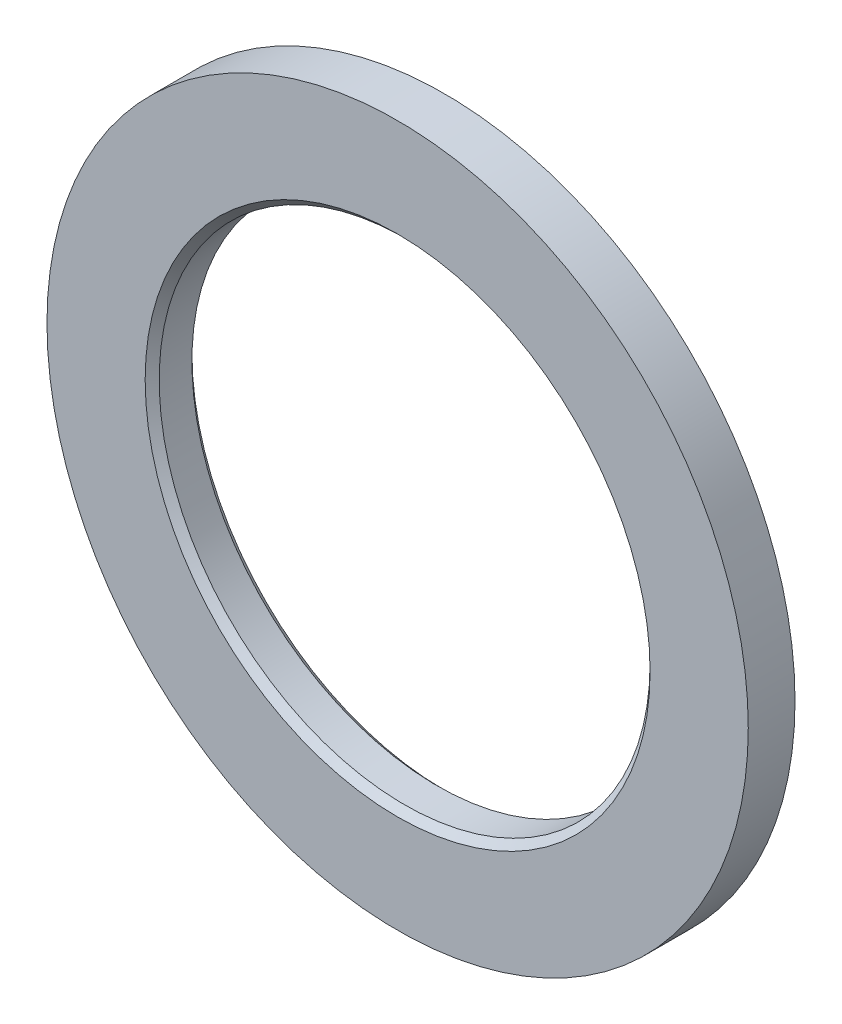
from build123d import *

# Parameters (mm, degrees)
GUARD_BASE_R     = 37.5
GUARD_DEPTH      = 5
AXLE_HOLE_BASE_R = 26.25
AXLE_HOLE_DEPTH  = 6


with BuildPart() as part:
    # Guard base → Guard (new body)
    with BuildSketch(Plane.XY):
        Circle(GUARD_BASE_R)
    extrude(amount=GUARD_DEPTH)

    # Axle hole base → Axle hole (cut, through all)
    with BuildSketch(Plane.XY.offset(5)):
        Circle(AXLE_HOLE_BASE_R)
    extrude(amount=-AXLE_HOLE_DEPTH, mode=Mode.SUBTRACT)

    # Mate ring room base → Mate ring room (revolve, cut)
    with BuildSketch(Plane(origin=(0, 0, 0), x_dir=(1, 0, 0), z_dir=(0, 1, 0))):
        Polygon((26.25, -5), (27, -5), (26.25, -4.25), align=None)
        Polygon((26.25, 0), (27, 0), (26.25, -0.75), align=None)
    revolve(axis=Axis((0, 0, 0), (0, 0, -1)), mode=Mode.SUBTRACT)


solid = part.part
